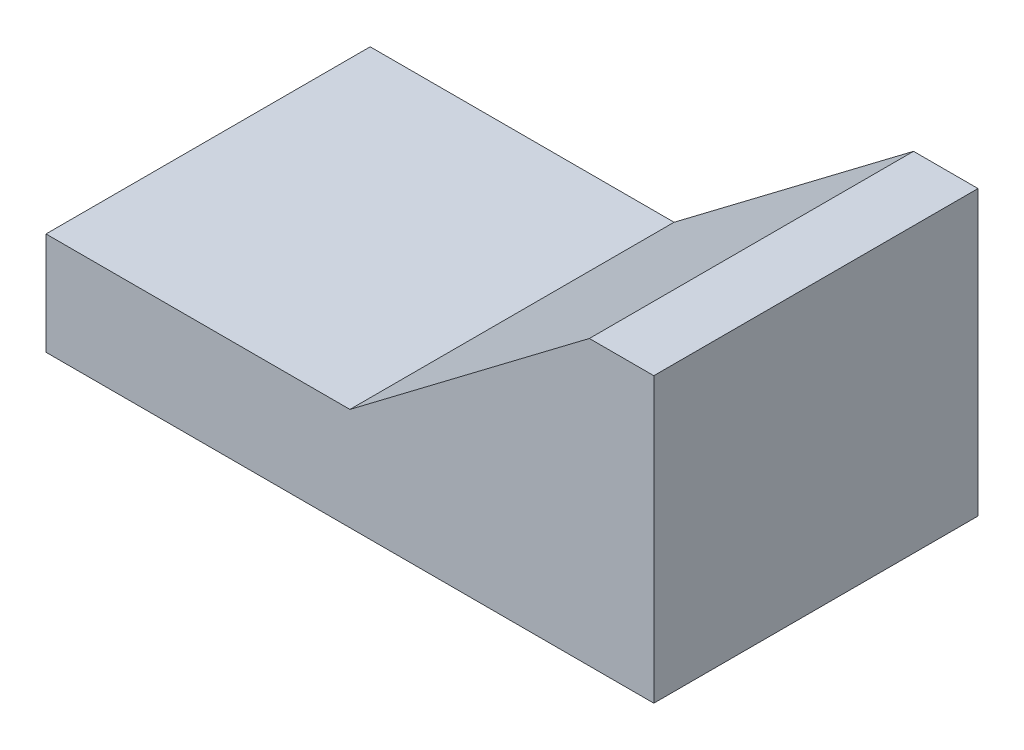
from build123d import *

# Parameters (mm, degrees)
Y_KSEKLIK_EKSTR_ZYON1_DEPTH = 8


with BuildPart() as part:
    # Çizim1 → Yükseklik-Ekstrüzyon1 (new body)
    with BuildSketch(Plane.XY):
        Polygon((-7.085141903, -1.5), (7.914858097, -1.5), (7.914858097, 5.5), (6.324218391, 5.5), (0.414858097, 1.029411765), (-7.085141903, 1.029411765), align=None)
    extrude(amount=Y_KSEKLIK_EKSTR_ZYON1_DEPTH)


solid = part.part
